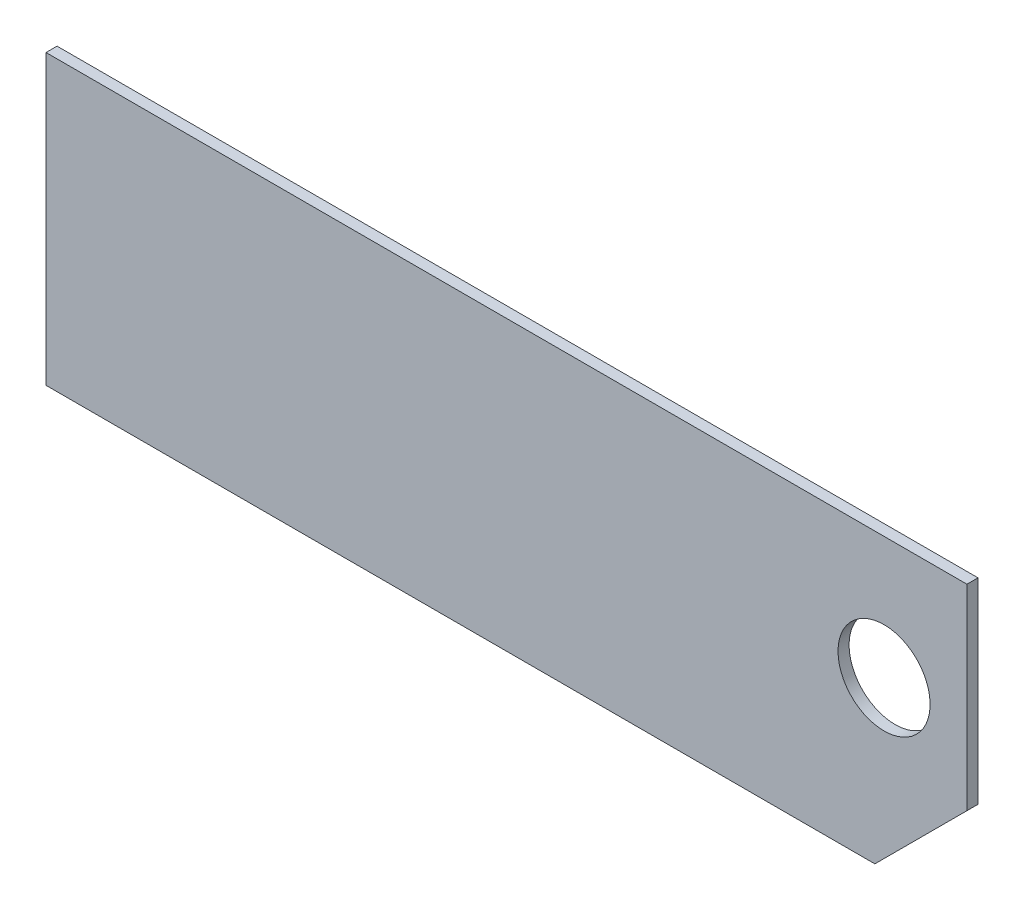
from build123d import *

# Parameters (mm, degrees)
SKETCH1_R           = 25
BOSS_EXTRUDE1_DEPTH = 6
SCALE1_SCALE        = 0.75


with BuildPart() as part:
    # Sketch1 → Boss-Extrude1 (new body)
    with BuildSketch(Plane.XY.offset(6)):
        Polygon((-200, -90), (250, -90), (300, -40), (300, 66.5), (-200, 66.5), align=None)
        with Locations((255, 0)):
            Circle(SKETCH1_R, mode=Mode.SUBTRACT)
    extrude(amount=-BOSS_EXTRUDE1_DEPTH)


with BuildPart() as part_1:
    # Scale1: scaled about (40.748726514, -11.031575069, 3)
    add(part.part.scale(SCALE1_SCALE).moved(Location((10.187181628, -2.757893767, 0.75))))


solid = part_1.part
